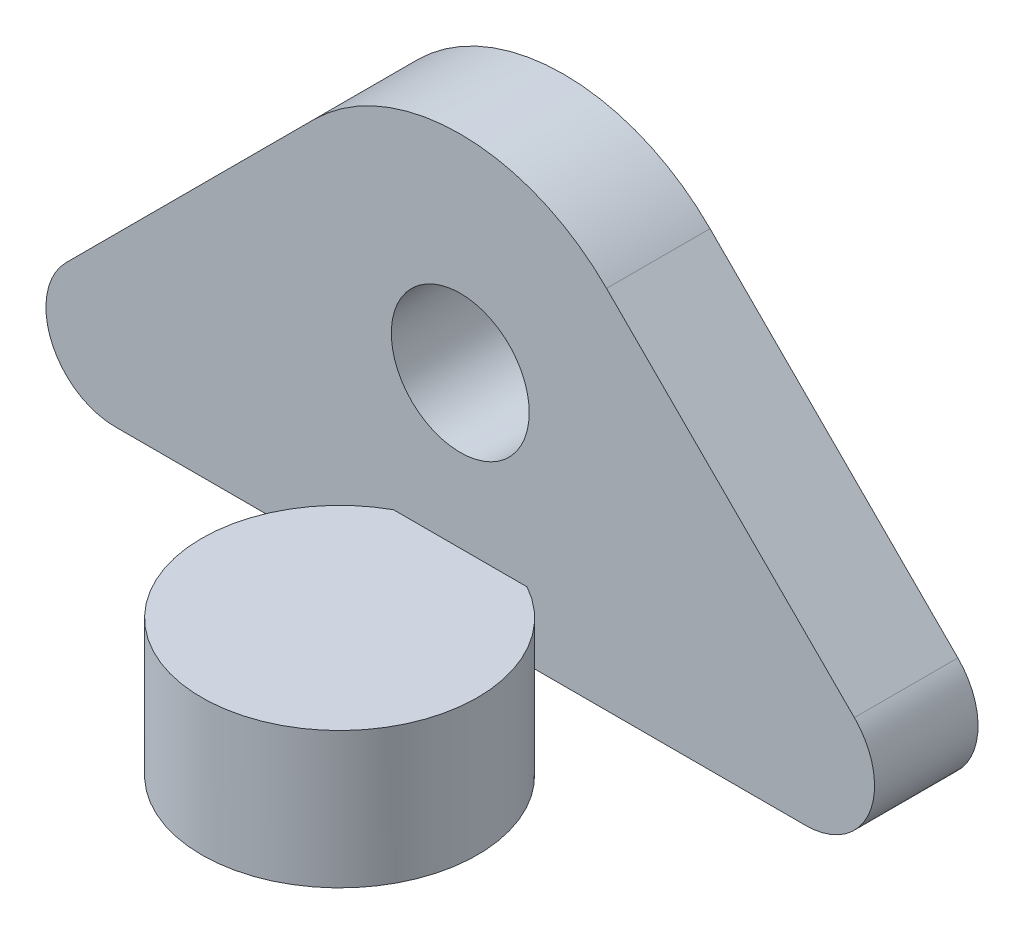
from build123d import *

# Parameters (mm, degrees)
SKETCH1_R                = 1.6129
BOSS_EXTRUDE1_DEPTH      = 2.42062
SKETCH2_R                = 3.2258
BOSS_EXTRUDE2_DEPTH      = 1.6129
BOSS_EXTRUDE2_DEPTH_BACK = 1.5748
SKETCH3_R                = 2.42062
CUT_EXTRUDE1_DEPTH       = 2.42062


with BuildPart() as part:
    # Sketch1 → Boss-Extrude1 (new body)
    with BuildSketch(Plane.XY):
        with BuildLine():
            Line((-8.0772, -5.12826), (8.0772, -5.12826))
            ThreePointArc((8.0772, -5.12826), (9.567321834, -4.13259847), (9.217705328, -2.374880273))
            Line((9.217705328, -2.374880273), (3.421515983, 3.421439181))
            ThreePointArc((3.421515983, 3.421439181), (0, 4.8387), (-3.421515983, 3.421439181))
            Line((-3.421515983, 3.421439181), (-9.217705328, -2.374880273))
            ThreePointArc((-9.217705328, -2.374880273), (-9.567321834, -4.13259847), (-8.0772, -5.12826))
        make_face()
        Circle(SKETCH1_R, mode=Mode.SUBTRACT)
    extrude(amount=-BOSS_EXTRUDE1_DEPTH)

    # Sketch2 → Boss-Extrude2 (add, two sides)
    with BuildSketch(Plane.XZ.offset(5.12826)) as boss_extrude2_sk:
        with Locations((0, 2.82194)):
            Circle(SKETCH2_R)
    extrude(amount=BOSS_EXTRUDE2_DEPTH)
    extrude(boss_extrude2_sk.sketch, amount=-BOSS_EXTRUDE2_DEPTH_BACK)

    # Sketch3 → Cut-Extrude1 (cut)
    with BuildSketch(Plane.XZ.offset(6.74116)):
        with Locations((0, 2.82194)):
            Circle(SKETCH3_R)
    extrude(amount=-CUT_EXTRUDE1_DEPTH, mode=Mode.SUBTRACT)


solid = part.part
